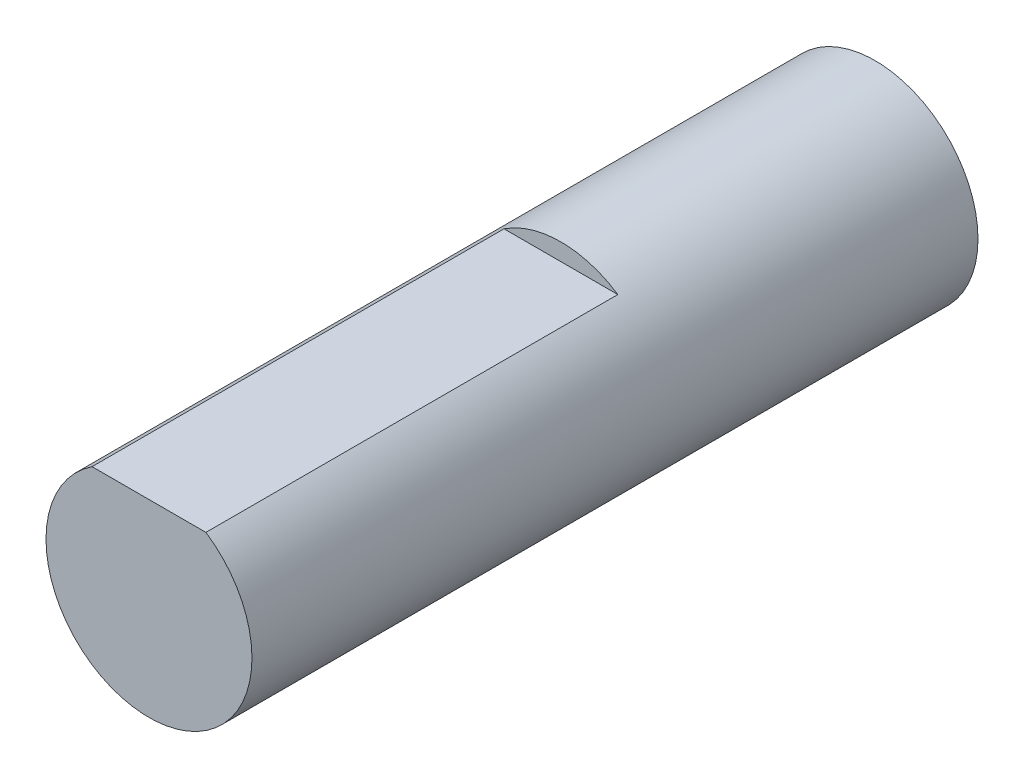
from build123d import *

# Parameters (mm, degrees)
SKETCH1_R           = 3
BOSS_EXTRUDE1_DEPTH = 21.15
SKETCH2_W           = 3.31662479
SKETCH2_H           = 0.5
CUT_EXTRUDE1_DEPTH  = 12


with BuildPart() as part:
    # Sketch1 → Boss-Extrude1 (new body)
    with BuildSketch(Plane.XY):
        Circle(SKETCH1_R)
    extrude(amount=BOSS_EXTRUDE1_DEPTH)

    # Sketch2 → Cut-Extrude1 (cut)
    with BuildSketch(Plane.XY.offset(21.15)):
        with Locations((0, 2.75)):
            Rectangle(SKETCH2_W, SKETCH2_H)
    extrude(amount=-CUT_EXTRUDE1_DEPTH, mode=Mode.SUBTRACT)


solid = part.part
